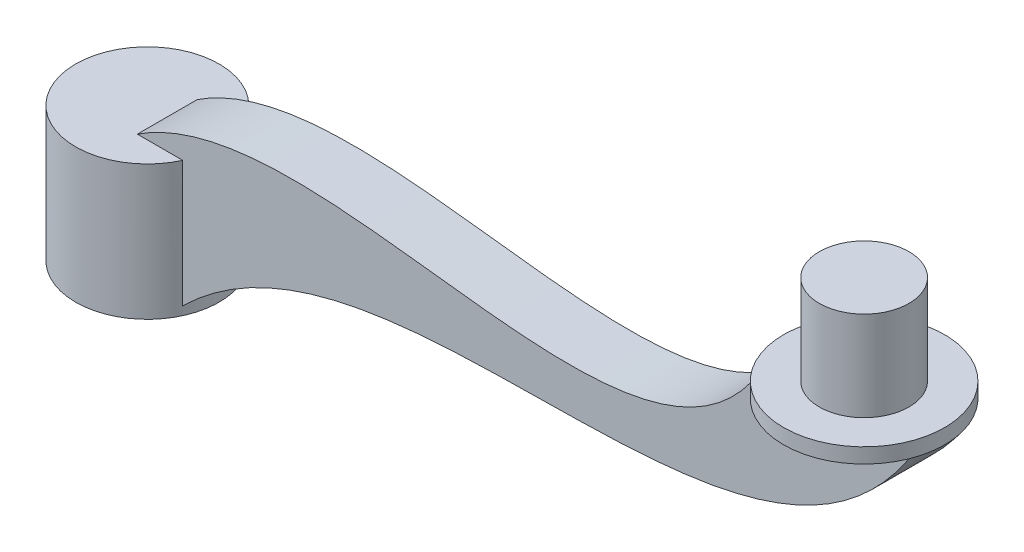
from build123d import *

# Parameters (mm, degrees)
BOSS_EXTRUDE1_START = 7.5
SKETCH1_R           = 12
SKETCH1_R_2         = 7.5005
BOSS_EXTRUDE1_DEPTH = 20
BOSS_EXTRUDE2_DEPTH = 5
BOSS_EXTRUDE3_START = 27.5
SKETCH1_2_R         = 12
SKETCH1_2_R_2       = 7.5005
BOSS_EXTRUDE3_DEPTH = 2.5
SKETCH3_R           = 13.462912018
BOSS_EXTRUDE4_DEPTH = 2.5
SKETCH5_R           = 7.5
BOSS_EXTRUDE5_DEPTH = 15


with BuildPart() as part:
    # Sketch1 → Boss-Extrude1 (new body)
    with BuildSketch(Plane(origin=(0, 0, 0), x_dir=(1, 0, 0), z_dir=(0, 1, 0)).offset(BOSS_EXTRUDE1_START)):
        Circle(SKETCH1_R)
        Circle(SKETCH1_R_2, mode=Mode.SUBTRACT)
    extrude(amount=BOSS_EXTRUDE1_DEPTH)

    # Sketch2 → Boss-Extrude2 (add, symmetric)
    with BuildSketch(Plane.XY):
        with BuildLine():
            Line((0, 27.5), (8.9613053, 27.5))
            Line((8.9613053, 27.5), (8.9613053, 6.915260629))
            add(Edge.make_bspline(
                [(8.9613053, 6.915260629), (42.430030167, 43.623802214), (104.826512854, 5.893256195), (132.347009744, 47.5)],
                knots=[0, 0, 0, 0, 1, 1, 1, 1], degree=3))
            Line((132.347009744, 47.5), (107.347009744, 47.5))
            add(Edge.make_bspline(
                [(0, 27.5), (29.095772849, 52.440117374), (86.574153169, 13.532011579), (107.347009744, 47.5)],
                knots=[0, 0, 0, 0, 1, 1, 1, 1], degree=3))
        make_face()
    extrude(amount=BOSS_EXTRUDE2_DEPTH, both=True)

    # Sketch1_2 → Boss-Extrude3 (add)
    with BuildSketch(Plane(origin=(0, 0, 0), x_dir=(1, 0, 0), z_dir=(0, 1, 0)).offset(BOSS_EXTRUDE3_START)):
        Circle(SKETCH1_2_R)
        Circle(SKETCH1_2_R_2, mode=Mode.SUBTRACT)
        Circle(SKETCH1_2_R_2)
    extrude(amount=BOSS_EXTRUDE3_DEPTH)

    # Sketch3 → Boss-Extrude4 (add)
    with BuildSketch(Plane(origin=(0, 47.5, 0), x_dir=(1, 0, 0), z_dir=(0, 1, 0))):
        with Locations((119.847009744, 0)):
            Circle(SKETCH3_R)
    extrude(amount=BOSS_EXTRUDE4_DEPTH)

    # Sketch5 → Boss-Extrude5 (add)
    with BuildSketch(Plane(origin=(0, 50, 0), x_dir=(1, 0, 0), z_dir=(0, 1, 0))):
        with Locations((119.847009744, 0)):
            Circle(SKETCH5_R)
    extrude(amount=BOSS_EXTRUDE5_DEPTH)


solid = part.part
